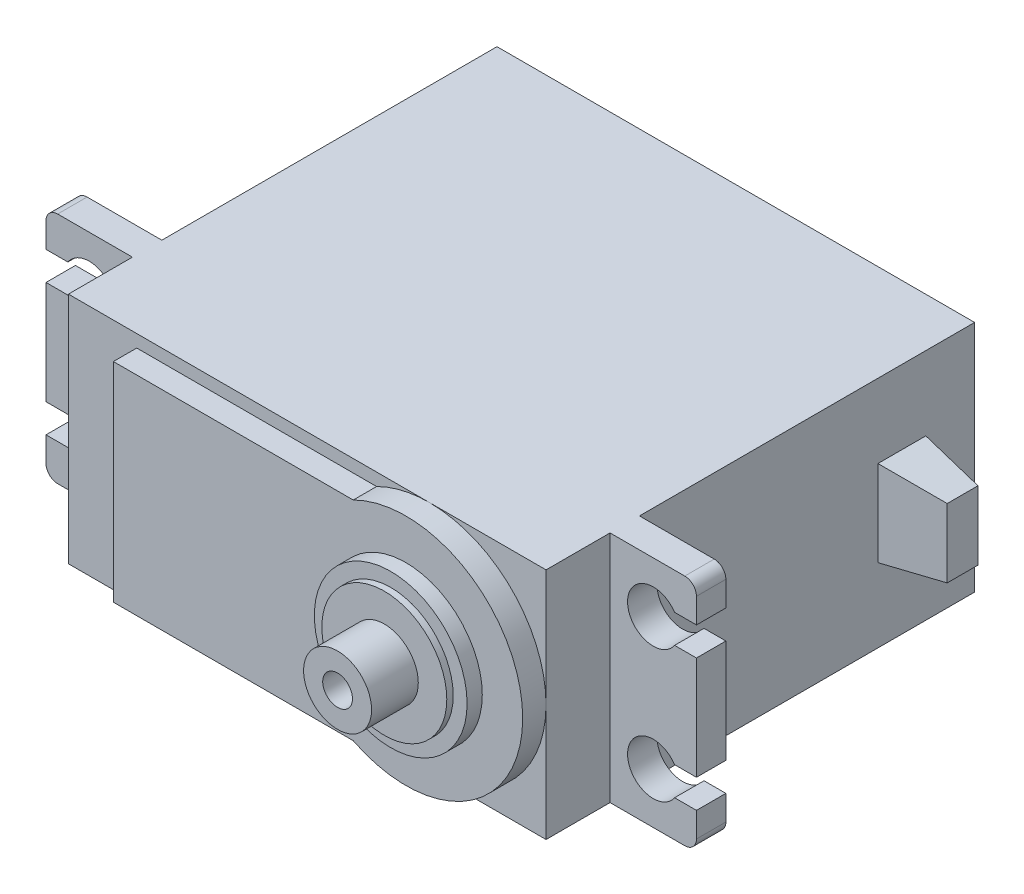
from build123d import *

# Parameters (mm, degrees)
SKETCH_1_W             = 40.9
SKETCH_1_H             = 20
EXTRUDE_1_DEPTH        = 36.7
SKETCH_2_R             = 10
EXTRUDE_2_DEPTH        = 2
SKETCH_3_R             = 6.54
EXTRUDE_3_DEPTH        = 1.3
SKETCH_4_R             = 5.35
EXTRUDE_4_DEPTH        = 0.55
SKETCH_5_R             = 2.91
SKETCH_5_R_2           = 1.275
EXTRUDE_5_DEPTH        = 4
EXTRUDE_6_DEPTH        = 2
SKETCH_7_W             = 2.52
SKETCH_7_H             = 20
EXTRUDE_7_DEPTH        = 7.4
CUT_EXTRUDE_3_DEPTH    = 3.4
FILLET_1_R             = 1
FILLET_1_OF_MIRROR_1_R = 1
SKETCH_9_W             = 4.1
SKETCH_9_H             = 7.35
EXTRUDE_8_DEPTH        = 5.2
EXTRUDE_8_TAPER        = 8


with BuildPart() as part:
    # 스케치1 → 보스-돌출1 (new body)
    with BuildSketch(Plane.XY):
        Rectangle(SKETCH_1_W, SKETCH_1_H)
    extrude(amount=EXTRUDE_1_DEPTH)

    # 스케치2 → 보스-돌출2 (add)
    with BuildSketch(Plane.XY.offset(36.7)):
        with Locations((10.45, 0)):
            Circle(SKETCH_2_R)
    extrude(amount=EXTRUDE_2_DEPTH)

    # 스케치3 → 보스-돌출3 (add)
    with BuildSketch(Plane.XY.offset(38.7)):
        with Locations((10.45, 0)):
            Circle(SKETCH_3_R)
    extrude(amount=EXTRUDE_3_DEPTH)

    # 스케치4 → 보스-돌출4 (add)
    with BuildSketch(Plane.XY.offset(40)):
        with Locations((10.45, 0)):
            Circle(SKETCH_4_R)
    extrude(amount=EXTRUDE_4_DEPTH)

    # 스케치5 → 보스-돌출5 (add)
    with BuildSketch(Plane.XY.offset(40.55)):
        with Locations((10.45, 0)):
            Circle(SKETCH_5_R)
        with Locations((10.45, 0)):
            Circle(SKETCH_5_R_2, mode=Mode.SUBTRACT)
    extrude(amount=EXTRUDE_5_DEPTH)

    # 스케치6 → 보스-돌출6 (add)
    with BuildSketch(Plane.XY.offset(36.7)):
        with BuildLine():
            Line((5.939526078, 8.925), (-14.6, 8.925))
            Line((-14.6, 8.925), (-14.6, -8.925))
            Line((-14.6, -8.925), (5.939526078, -8.925))
            ThreePointArc((5.939526078, -8.925), (0.45, 0), (5.939526078, 8.925))
        make_face()
    extrude(amount=EXTRUDE_6_DEPTH)

    # 스케치7 → 보스-돌출7 (add)
    with BuildSketch(Plane(origin=(20.45, 0, 0), x_dir=(0, 0, -1), z_dir=(1, 0, 0))):
        with Locations((-29.96, 0)):
            Rectangle(SKETCH_7_W, SKETCH_7_H)
    extrude_7 = extrude(amount=EXTRUDE_7_DEPTH)

    # 스케치8 → 컷-돌출3 (cut)
    with BuildSketch(Plane.XY.offset(31.22)):
        with BuildLine():
            Line((27.85, 6.875), (27.85, 4.425))
            Line((27.85, 4.425), (25.977395688, 4.425))
            ThreePointArc((25.977395688, 4.425), (21.95, 5.65), (25.977395688, 6.875))
            Line((25.977395688, 6.875), (27.85, 6.875))
        make_face()
        with BuildLine():
            Line((27.85, -4.425), (27.85, -6.875))
            Line((27.85, -6.875), (25.977395688, -6.875))
            ThreePointArc((25.977395688, -6.875), (21.95, -5.65), (25.977395688, -4.425))
            Line((25.977395688, -4.425), (27.85, -4.425))
        make_face()
    cut_extrude_3 = extrude(amount=-CUT_EXTRUDE_3_DEPTH, mode=Mode.SUBTRACT)

    # 필렛1
    fillet_1_edges = [part.edges().sort_by_distance(p)[0] for p in [
        (27.85, -10, 29.96),
        (27.85, 10, 29.96),
    ]]
    fillet(fillet_1_edges, radius=FILLET_1_R)

    # 대칭 복사1: 보스-돌출7, 컷-돌출3 across plane
    add(extrude_7.mirror(Plane(origin=(0, 0, 0), x_dir=(0, 0, 1), z_dir=(1, 0, 0))))
    add(cut_extrude_3.mirror(Plane(origin=(0, 0, 0), x_dir=(0, 0, 1), z_dir=(1, 0, 0))), mode=Mode.SUBTRACT)

    # 필렛1 of 대칭 복사1
    fillet_1_of_mirror_1_edges = [part.edges().sort_by_distance(p)[0] for p in [
        (-27.85, -10, 29.96),
        (-27.85, 10, 29.96),
    ]]
    fillet(fillet_1_of_mirror_1_edges, radius=FILLET_1_OF_MIRROR_1_R)

    # 스케치9 → 보스-돌출8 (add)
    with BuildSketch(Plane(origin=(20.45, 0, 0), x_dir=(0, 0, -1), z_dir=(1, 0, 0))):
        with Locations((-6.23, 0)):
            Rectangle(SKETCH_9_W, SKETCH_9_H)
    extrude(amount=EXTRUDE_8_DEPTH, taper=EXTRUDE_8_TAPER)


solid = part.part
